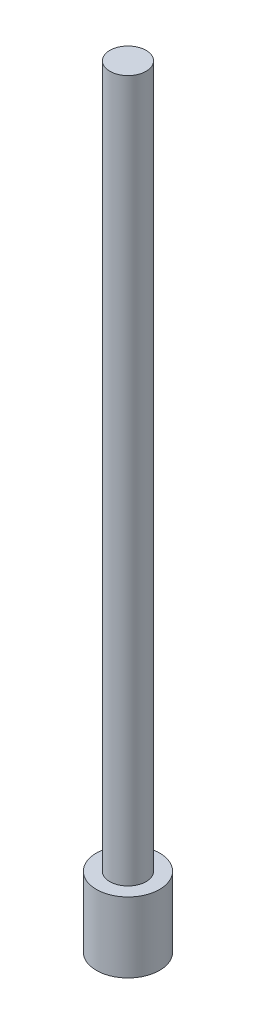
from build123d import *

# Parameters (mm, degrees)
SKETCH1_R           = 7.75
BOSS_EXTRUDE1_DEPTH = 300
SKETCH2_R           = 13.5
BOSS_EXTRUDE2_DEPTH = 30


with BuildPart() as part:
    # Sketch1 → Boss-Extrude1 (new body)
    with BuildSketch(Plane(origin=(0, 0, 0), x_dir=(1, 0, 0), z_dir=(0, 1, 0))):
        Circle(SKETCH1_R)
    extrude(amount=BOSS_EXTRUDE1_DEPTH)

    # Sketch2 → Boss-Extrude2 (add)
    with BuildSketch(Plane(origin=(0, 0, 0), x_dir=(1, 0, 0), z_dir=(0, 1, 0))):
        Circle(SKETCH2_R)
    extrude(amount=-BOSS_EXTRUDE2_DEPTH)


solid = part.part
